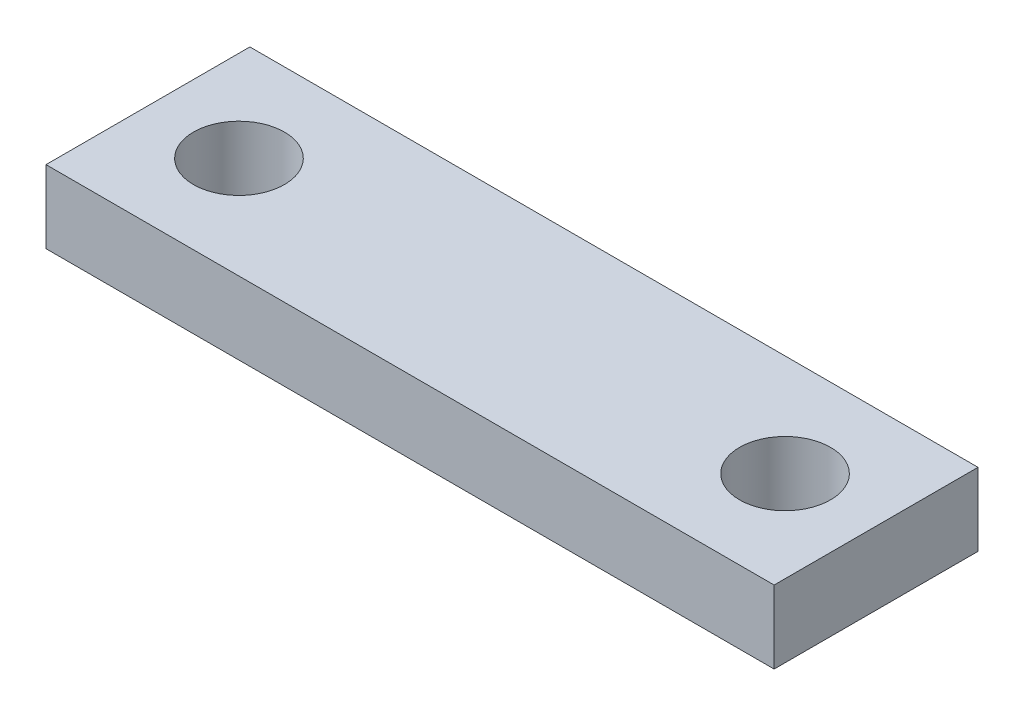
from build123d import *

# Parameters (mm, degrees)
SKETCH1_W           = 40
SKETCH1_H           = 11.2
SKETCH1_R           = 2.5
BOSS_EXTRUDE2_DEPTH = 4


with BuildPart() as part:
    # Sketch1 → Boss-Extrude2 (new body)
    with BuildSketch(Plane(origin=(0, 0, 0), x_dir=(1, 0, 0), z_dir=(0, 1, 0))):
        Rectangle(SKETCH1_W, SKETCH1_H)
        with Locations((-15, 0)):
            Circle(SKETCH1_R, mode=Mode.SUBTRACT)
        with Locations((15, 0)):
            Circle(SKETCH1_R, mode=Mode.SUBTRACT)
    extrude(amount=BOSS_EXTRUDE2_DEPTH)


solid = part.part
